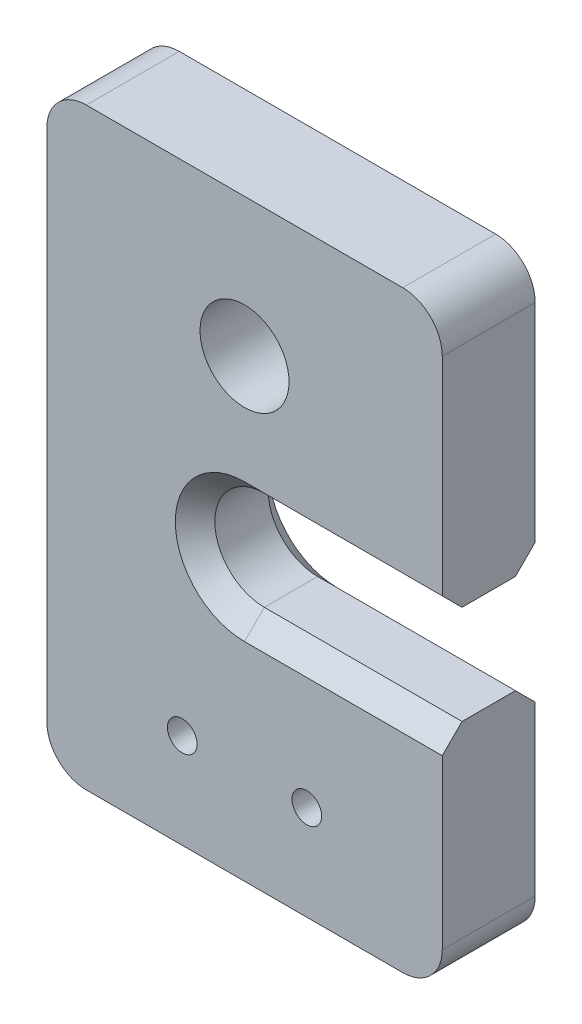
from build123d import *

# Parameters (mm, degrees)
SKETCH1_R           = 2.25
SKETCH1_R_2         = 0.75
BOSS_EXTRUDE1_DEPTH = 4.7
CUT_EXTRUDE1_DEPTH  = 5.7
CHAMFER1_SIZE       = 1


with BuildPart() as part:
    # Sketch1 → Boss-Extrude1 (new body)
    with BuildSketch(Plane.XY):
        with BuildLine():
            Line((2, 0), (18, 0))
            ThreePointArc((18, 0), (19.414213562, 0.585786438), (20, 2))
            Line((20, 2), (20, 28))
            ThreePointArc((20, 28), (19.414213562, 29.414213562), (18, 30))
            Line((18, 30), (2, 30))
            ThreePointArc((2, 30), (0.585786438, 29.414213562), (0, 28))
            Line((0, 28), (0, 2))
            ThreePointArc((0, 2), (0.585786438, 0.585786438), (2, 0))
        make_face()
        with Locations((10, 23)):
            Circle(SKETCH1_R, mode=Mode.SUBTRACT)
        with Locations((6.85, 4.8)):
            Circle(SKETCH1_R_2, mode=Mode.SUBTRACT)
        with Locations((13.15, 4.8)):
            Circle(SKETCH1_R_2, mode=Mode.SUBTRACT)
    extrude(amount=BOSS_EXTRUDE1_DEPTH)

    # Sketch2 → Cut-Extrude1 (cut, through all)
    with BuildSketch(Plane.XY.offset(4.7)):
        with BuildLine():
            Line((20, 16.5), (10, 16.5))
            ThreePointArc((10, 16.5), (7.5, 14), (10, 11.5))
            Line((10, 11.5), (20, 11.5))
            Line((20, 11.5), (20, 16.5))
        make_face()
    extrude(amount=-CUT_EXTRUDE1_DEPTH, mode=Mode.SUBTRACT)

    # Chamfer1
    chamfer1_edges = [part.edges().sort_by_distance(p)[0] for p in [
        (15, 11.5, 0),
        (7.5, 14, 0),
        (15, 16.5, 0),
        (15, 16.5, 4.7),
        (7.5, 14, 4.7),
        (15, 11.5, 4.7),
    ]]
    chamfer(chamfer1_edges, length=CHAMFER1_SIZE)


solid = part.part
